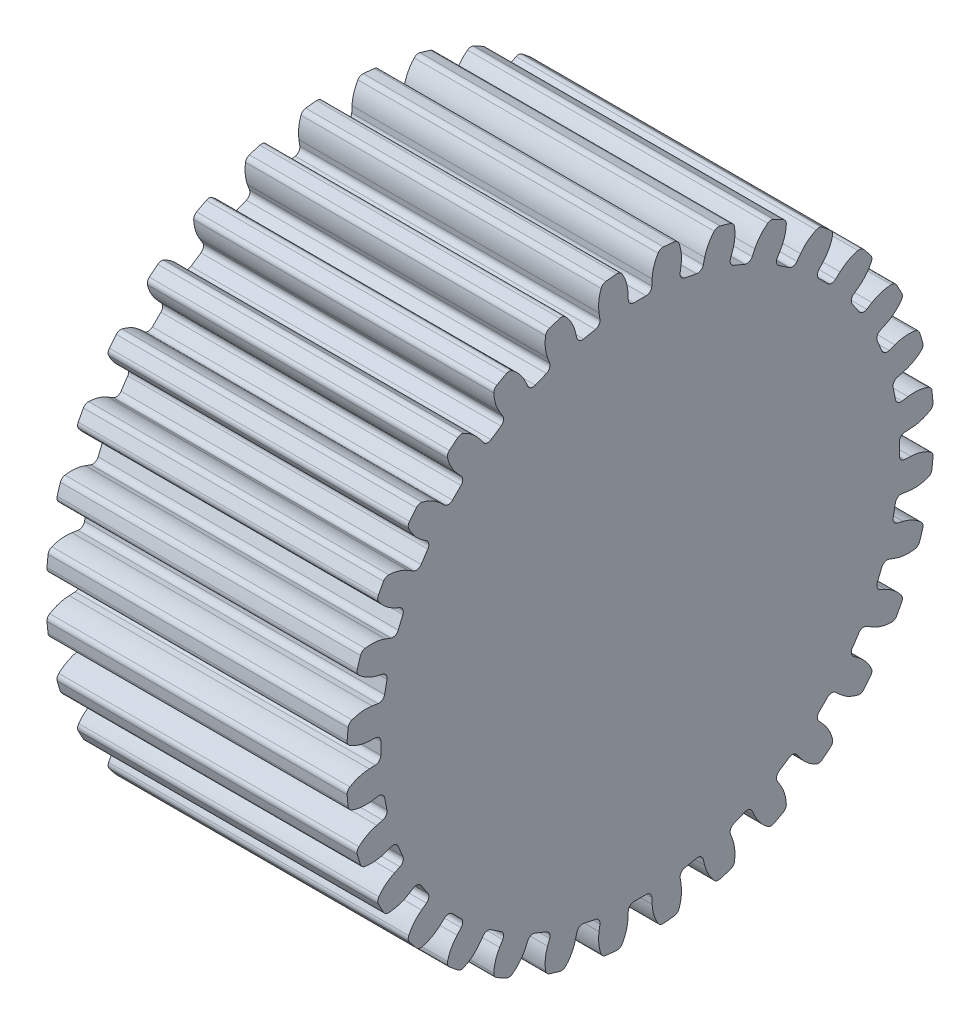
from build123d import *

# Parameters (mm, degrees)
ESQUISSE1_R                        = 12.73
EXTRUSION1_DEPTH                   = 13
ENL_V_MAT_EXTRU_2_DEPTH            = 13
CONG_2_R                           = 0.25
R_P_TITION_CIRCULAIRE1_COUNT       = 32
CONG_2_OF_R_P_TITION_CIRCULAIRE1_R = 0.25


with BuildPart() as part:
    # Esquisse1 → Extrusion1 (new body)
    with BuildSketch(Plane(origin=(0, 0, 0), x_dir=(0, 0, -1), z_dir=(1, 0, 0))):
        Circle(ESQUISSE1_R)
    extrude(amount=EXTRUSION1_DEPTH)

    # Esquisse22 → Enlèv. mat.-Extru.2 (cut)
    with BuildSketch(Plane.ZY):
        with BuildLine():
            Line((-0.5, 11.23), (0.5, 11.23))
            Line((0.5, 11.23), (0.522261799, 11.73))
            ThreePointArc((0.522261799, 11.73), (0.621869561, 12.240897787), (0.866224446, 12.70049429))
            ThreePointArc((0.866224446, 12.70049429), (0, 12.73), (-0.866224446, 12.70049429))
            ThreePointArc((-0.866224446, 12.70049429), (-0.621869561, 12.240897787), (-0.522261799, 11.73))
            Line((-0.522261799, 11.73), (-0.5, 11.23))
        make_face()
    enl_v_mat_extru_2 = extrude(amount=-ENL_V_MAT_EXTRU_2_DEPTH, mode=Mode.SUBTRACT)

    # Congé2
    cong_2_edges = [part.edges().sort_by_distance(p)[0] for p in [
        (6.5, 11.23, -0.5),
        (6.5, 12.70049429, -0.866224446),
        (6.5, 12.70049429, 0.866224446),
        (6.5, 11.23, 0.5),
    ]]
    fillet(cong_2_edges, radius=CONG_2_R)

    # Répétition circulaire1: Enlèv. mat.-Extru.2 ×32 about axis
    r_p_tition_circulaire1_axis = Axis((0, 0, 0), (1, 0, 0))
    for i in range(1, R_P_TITION_CIRCULAIRE1_COUNT):
        add(enl_v_mat_extru_2.rotate(r_p_tition_circulaire1_axis, i * 360 / R_P_TITION_CIRCULAIRE1_COUNT), mode=Mode.SUBTRACT)

    # Congé2 of Répétition circulaire1
    cong_2_of_r_p_tition_circulaire1_edges = [part.edges().sort_by_distance(p)[0] for p in [
        (6.5, 11.11176386, 1.700471676),
        (6.5, 12.62544986, 1.628163334),
        (6.5, 12.287465847, 3.327323707),
        (6.5, 10.916673538, 2.681256956),
        (6.5, 10.566508866, 3.835595179),
        (6.5, 12.065216472, 4.059981711),
        (6.5, 11.402236983, 5.660555784),
        (6.5, 10.183825434, 4.759474712),
        (6.5, 9.615188863, 5.823318911),
        (6.5, 11.041323581, 6.335777268),
        (6.5, 10.078826546, 7.776255877),
        (6.5, 9.05961863, 6.654788523),
        (6.5, 8.294362543, 7.587255762),
        (6.5, 9.593118817, 8.368092457),
        (6.5, 8.368092457, 9.593118817),
        (6.5, 7.587255762, 8.294362543),
        (6.5, 6.654788523, 9.05961863),
        (6.5, 7.776255877, 10.078826546),
        (6.5, 6.335777268, 11.041323581),
        (6.5, 5.823318911, 9.615188863),
        (6.5, 4.759474712, 10.183825434),
        (6.5, 5.660555784, 11.402236983),
        (6.5, 4.059981711, 12.065216472),
        (6.5, 3.835595179, 10.566508866),
        (6.5, 2.681256956, 10.916673538),
        (6.5, 3.327323707, 12.287465847),
        (6.5, 1.628163334, 12.62544986),
        (6.5, 1.700471676, 11.11176386),
        (6.5, 0.5, 11.23),
        (6.5, 0.866224446, 12.70049429),
        (6.5, -0.866224446, 12.70049429),
        (6.5, -0.5, 11.23),
        (6.5, -1.700471676, 11.11176386),
        (6.5, -1.628163334, 12.62544986),
        (6.5, -3.327323707, 12.287465847),
        (6.5, -2.681256956, 10.916673538),
        (6.5, -3.835595179, 10.566508866),
        (6.5, -4.059981711, 12.065216472),
        (6.5, -5.660555784, 11.402236983),
        (6.5, -4.759474712, 10.183825434),
        (6.5, -5.823318911, 9.615188863),
        (6.5, -6.335777268, 11.041323581),
        (6.5, -7.776255877, 10.078826546),
        (6.5, -6.654788523, 9.05961863),
        (6.5, -7.587255762, 8.294362543),
        (6.5, -8.368092457, 9.593118817),
        (6.5, -9.593118817, 8.368092457),
        (6.5, -8.294362543, 7.587255762),
        (6.5, -9.05961863, 6.654788523),
        (6.5, -10.078826546, 7.776255877),
        (6.5, -11.041323581, 6.335777268),
        (6.5, -9.615188863, 5.823318911),
        (6.5, -10.183825434, 4.759474712),
        (6.5, -11.402236983, 5.660555784),
        (6.5, -12.065216472, 4.059981711),
        (6.5, -10.566508866, 3.835595179),
        (6.5, -10.916673538, 2.681256956),
        (6.5, -12.287465847, 3.327323707),
        (6.5, -12.62544986, 1.628163334),
        (6.5, -11.11176386, 1.700471676),
        (6.5, -11.23, 0.5),
        (6.5, -12.70049429, 0.866224446),
        (6.5, -12.70049429, -0.866224446),
        (6.5, -11.23, -0.5),
        (6.5, -11.11176386, -1.700471676),
        (6.5, -12.62544986, -1.628163334),
        (6.5, -12.287465847, -3.327323707),
        (6.5, -10.916673538, -2.681256956),
        (6.5, -10.566508866, -3.835595179),
        (6.5, -12.065216472, -4.059981711),
        (6.5, -11.402236983, -5.660555784),
        (6.5, -10.183825434, -4.759474712),
        (6.5, -9.615188863, -5.823318911),
        (6.5, -11.041323581, -6.335777268),
        (6.5, -10.078826546, -7.776255877),
        (6.5, -9.05961863, -6.654788523),
        (6.5, -8.294362543, -7.587255762),
        (6.5, -9.593118817, -8.368092457),
        (6.5, -8.368092457, -9.593118817),
        (6.5, -7.587255762, -8.294362543),
        (6.5, -6.654788523, -9.05961863),
        (6.5, -7.776255877, -10.078826546),
        (6.5, -6.335777268, -11.041323581),
        (6.5, -5.823318911, -9.615188863),
        (6.5, -4.759474712, -10.183825434),
        (6.5, -5.660555784, -11.402236983),
        (6.5, -4.059981711, -12.065216472),
        (6.5, -3.835595179, -10.566508866),
        (6.5, -2.681256956, -10.916673538),
        (6.5, -3.327323707, -12.287465847),
        (6.5, -1.628163334, -12.62544986),
        (6.5, -1.700471676, -11.11176386),
        (6.5, -0.5, -11.23),
        (6.5, -0.866224446, -12.70049429),
        (6.5, 0.866224446, -12.70049429),
        (6.5, 0.5, -11.23),
        (6.5, 1.700471676, -11.11176386),
        (6.5, 1.628163334, -12.62544986),
        (6.5, 3.327323707, -12.287465847),
        (6.5, 2.681256956, -10.916673538),
        (6.5, 3.835595179, -10.566508866),
        (6.5, 4.059981711, -12.065216472),
        (6.5, 5.660555784, -11.402236983),
        (6.5, 4.759474712, -10.183825434),
        (6.5, 5.823318911, -9.615188863),
        (6.5, 6.335777268, -11.041323581),
        (6.5, 7.776255877, -10.078826546),
        (6.5, 6.654788523, -9.05961863),
        (6.5, 7.587255762, -8.294362543),
        (6.5, 8.368092457, -9.593118817),
        (6.5, 9.593118817, -8.368092457),
        (6.5, 8.294362543, -7.587255762),
        (6.5, 9.05961863, -6.654788523),
        (6.5, 10.078826546, -7.776255877),
        (6.5, 11.041323581, -6.335777268),
        (6.5, 9.615188863, -5.823318911),
        (6.5, 10.183825434, -4.759474712),
        (6.5, 11.402236983, -5.660555784),
        (6.5, 12.065216472, -4.059981711),
        (6.5, 10.566508866, -3.835595179),
        (6.5, 10.916673538, -2.681256956),
        (6.5, 12.287465847, -3.327323707),
        (6.5, 12.62544986, -1.628163334),
        (6.5, 11.11176386, -1.700471676),
    ]]
    fillet(cong_2_of_r_p_tition_circulaire1_edges, radius=CONG_2_OF_R_P_TITION_CIRCULAIRE1_R)


solid = part.part
